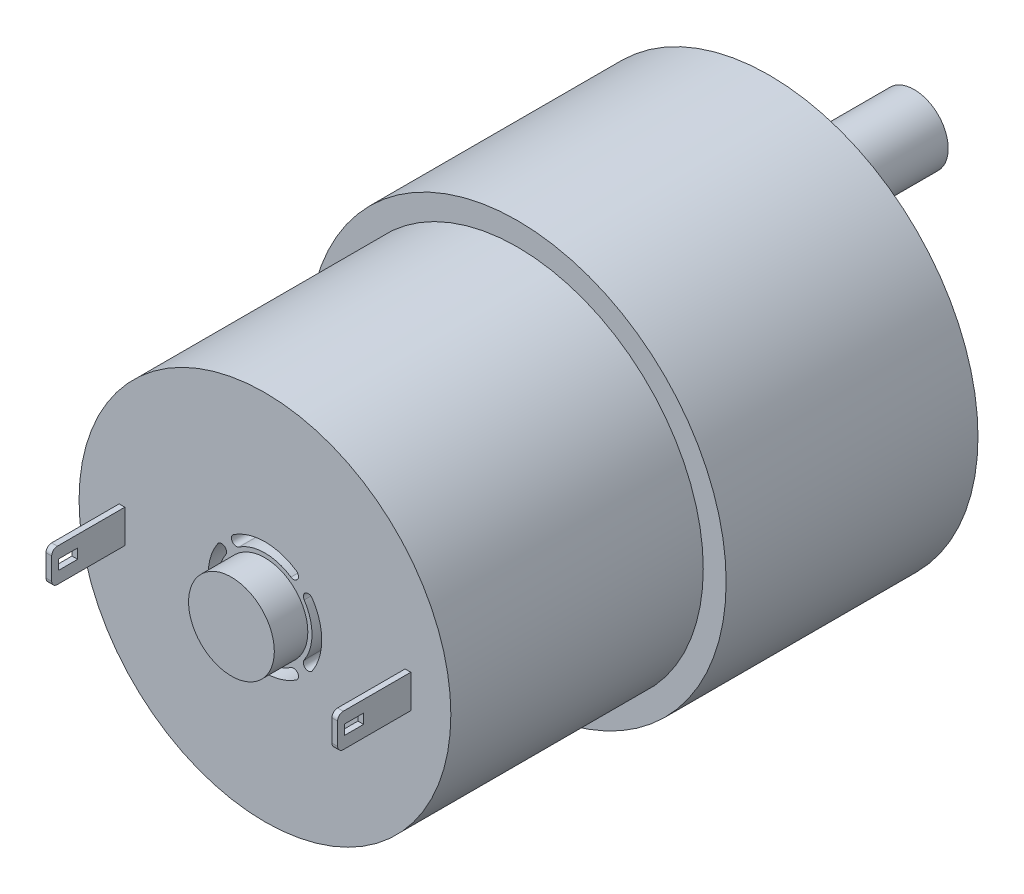
from build123d import *

# Parameters (mm, degrees)
SKETCH_1_R          = 18.38
EXTRUDE_1_DEPTH     = 22.17
SKETCH_2_R          = 16.365
EXTRUDE_2_DEPTH     = 22.22
SKETCH_3_R          = 5.98
EXTRUDE_3_DEPTH     = 5.7
SKETCH_4_R          = 3
EXTRUDE_4_DEPTH     = 14.96
SKETCH_5_W          = 1.304796907
SKETCH_5_H          = 4.648976657
CUT_EXTRUDE_1_DEPTH = 12
SKETCH_6_R          = 1.255
CUT_EXTRUDE_2_DEPTH = 3
CUT_EXTRUDE_3_DEPTH = 1
FILLET_1_R          = 0.5
FILLET_3_R          = 0.5
SKETCH_8_W          = 0.5
SKETCH_8_H          = 2.93
EXTRUDE_5_DEPTH     = 6.44
SKETCH_9_R          = 3.775
EXTRUDE_6_DEPTH     = 2.95
CUT_EXTRUDE_4_DEPTH = 2.95
SKETCH_11_W         = 1.680936825
SKETCH_11_H         = 0.866217562
CUT_EXTRUDE_5_DEPTH = 37.95
FILLET_4_R          = 0.5


with BuildPart() as part:
    # Эскиз1 → Бобышка-Вытянуть1 (new body)
    with BuildSketch(Plane.XY):
        Circle(SKETCH_1_R)
    extrude(amount=EXTRUDE_1_DEPTH)

    # Эскиз2 → Бобышка-Вытянуть2 (add)
    with BuildSketch(Plane.XY.offset(22.17)):
        Circle(SKETCH_2_R)
    extrude(amount=EXTRUDE_2_DEPTH)

    # Эскиз3 → Бобышка-Вытянуть3 (add)
    with BuildSketch(Plane(origin=(0, 0, 0), x_dir=(-1, 0, 0), z_dir=(0, 0, -1))):
        with Locations((7.9, 0)):
            Circle(SKETCH_3_R)
    extrude(amount=EXTRUDE_3_DEPTH)

    # Эскиз4 → Бобышка-Вытянуть4 (add)
    with BuildSketch(Plane(origin=(0, 0, -5.7), x_dir=(-1, 0, 0), z_dir=(0, 0, -1))):
        with Locations((7.9, 0)):
            Circle(SKETCH_4_R)
    extrude(amount=EXTRUDE_4_DEPTH)

    # Эскиз5 → Вырез-Вытянуть1 (cut)
    with BuildSketch(Plane(origin=(0, 0, -20.66), x_dir=(-1, 0, 0), z_dir=(0, 0, -1))):
        with Locations((11.042398454, -0.267988811)):
            Rectangle(SKETCH_5_W, SKETCH_5_H)
    extrude(amount=-CUT_EXTRUDE_1_DEPTH, mode=Mode.SUBTRACT)

    # Эскиз6 → Вырез-Вытянуть2 (cut)
    with BuildSketch(Plane(origin=(0, 0, 0), x_dir=(-1, 0, 0), z_dir=(0, 0, -1))):
        with Locations((0, -15.605)):
            Circle(SKETCH_6_R)
        with Locations((-13.514326426, -7.8025)):
            Circle(SKETCH_6_R)
        with Locations((-13.514326426, 7.8025)):
            Circle(SKETCH_6_R)
        with Locations((0, 15.605)):
            Circle(SKETCH_6_R)
        with Locations((13.514326426, 7.8025)):
            Circle(SKETCH_6_R)
        with Locations((13.514326426, -7.8025)):
            Circle(SKETCH_6_R)
    extrude(amount=-CUT_EXTRUDE_2_DEPTH, mode=Mode.SUBTRACT)

    # Эскиз7 → Вырез-Вытянуть3 (cut)
    with BuildSketch(Plane(origin=(0, 0, 0), x_dir=(-1, 0, 0), z_dir=(0, 0, -1))):
        with BuildLine():
            ThreePointArc((7.9, 6.731145279), (1.168854721, 0), (7.9, -6.731145279))
            ThreePointArc((7.9, -6.731145279), (-14.190210328, 0), (7.9, 6.731145279))
        make_face()
    extrude(amount=-CUT_EXTRUDE_3_DEPTH, mode=Mode.SUBTRACT)

    # Скругление1
    fillet_1_edges = [part.edges().sort_by_distance(p)[0] for p in [
        (14.190210328, 0, 1),
        (-1.168854721, 0, 1),
    ]]
    fillet(fillet_1_edges, radius=FILLET_1_R)

    # Скругление3
    fillet_3_edges = [part.edges().sort_by_distance(p)[0] for p in [
        (-1.92, 0, -5.7),
    ]]
    fillet(fillet_3_edges, radius=FILLET_3_R)

    # Эскиз8 → Бобышка-Вытянуть5 (add)
    with BuildSketch(Plane.XY.offset(44.39)):
        with Locations((-12.585, 0)):
            Rectangle(SKETCH_8_W, SKETCH_8_H)
        with Locations((12.585, 0)):
            Rectangle(SKETCH_8_W, SKETCH_8_H)
    extrude(amount=EXTRUDE_5_DEPTH)

    # Эскиз9 → Бобышка-Вытянуть6 (add)
    with BuildSketch(Plane.XY.offset(44.39)):
        Circle(SKETCH_9_R)
    extrude(amount=EXTRUDE_6_DEPTH)

    # Эскиз10 → Вырез-Вытянуть4 (cut)
    with BuildSketch(Plane.XY.offset(44.39)):
        with BuildLine():
            ThreePointArc((-4.166478649, 2.760889391), (-4.998205134, 0), (-4.166478649, -2.760889391))
            ThreePointArc((-4.166478649, -2.760889391), (-3.573206608, -2.881623675), (-3.451786459, -2.288491624))
            ThreePointArc((-3.451786459, -2.288491624), (-4.141500171, 0), (-3.451786459, 2.288491624))
            ThreePointArc((-3.451786459, 2.288491624), (-3.573206608, 2.881623675), (-4.166478649, 2.760889391))
        make_face()
        with BuildLine():
            ThreePointArc((2.760889391, 4.166478649), (0, 4.998205134), (-2.760889391, 4.166478649))
            ThreePointArc((-2.760889391, 4.166478649), (-2.881623675, 3.573206608), (-2.288491624, 3.451786459))
            ThreePointArc((-2.288491624, 3.451786459), (0, 4.141500171), (2.288491624, 3.451786459))
            ThreePointArc((2.288491624, 3.451786459), (2.881623675, 3.573206608), (2.760889391, 4.166478649))
        make_face()
        with BuildLine():
            ThreePointArc((4.166478649, -2.760889391), (4.998205134, 0), (4.166478649, 2.760889391))
            ThreePointArc((4.166478649, 2.760889391), (3.573206608, 2.881623675), (3.451786459, 2.288491624))
            ThreePointArc((3.451786459, 2.288491624), (4.141500171, 0), (3.451786459, -2.288491624))
            ThreePointArc((3.451786459, -2.288491624), (3.573206608, -2.881623675), (4.166478649, -2.760889391))
        make_face()
        with BuildLine():
            ThreePointArc((-2.760889391, -4.166478649), (0, -4.998205134), (2.760889391, -4.166478649))
            ThreePointArc((2.760889391, -4.166478649), (2.881623675, -3.573206608), (2.288491624, -3.451786459))
            ThreePointArc((2.288491624, -3.451786459), (0, -4.141500171), (-2.288491624, -3.451786459))
            ThreePointArc((-2.288491624, -3.451786459), (-2.881623675, -3.573206608), (-2.760889391, -4.166478649))
        make_face()
    extrude(amount=-CUT_EXTRUDE_4_DEPTH, mode=Mode.SUBTRACT)

    # Эскиз11 → Вырез-Вытянуть5 (cut)
    with BuildSketch(Plane.ZY.offset(12.835)):
        with Locations((49.383028143, 0)):
            Rectangle(SKETCH_11_W, SKETCH_11_H)
    extrude(amount=-CUT_EXTRUDE_5_DEPTH, mode=Mode.SUBTRACT)

    # Скругление4
    fillet_4_edges = [part.edges().sort_by_distance(p)[0] for p in [
        (-12.585, 1.465, 50.83),
        (-12.585, -1.465, 50.83),
        (12.585, 1.465, 50.83),
        (12.585, -1.465, 50.83),
    ]]
    fillet(fillet_4_edges, radius=FILLET_4_R)


solid = part.part
